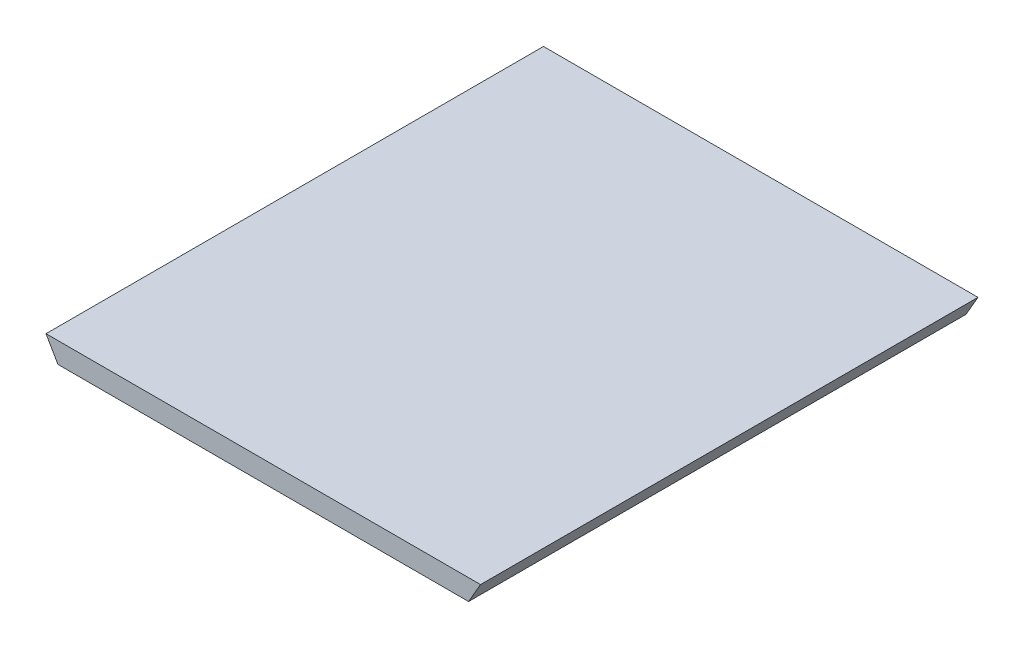
from build123d import *

# Parameters (mm, degrees)
BOSS_EXTRUDE1_DEPTH = 36.1


with BuildPart() as part:
    # Sketch1 → Boss-Extrude1 (new body)
    with BuildSketch(Plane.XY):
        Polygon((-14.9, 0), (14.9, 0), (15.766025404, 1.5), (-15.766025404, 1.5), align=None)
    extrude(amount=BOSS_EXTRUDE1_DEPTH)


solid = part.part
